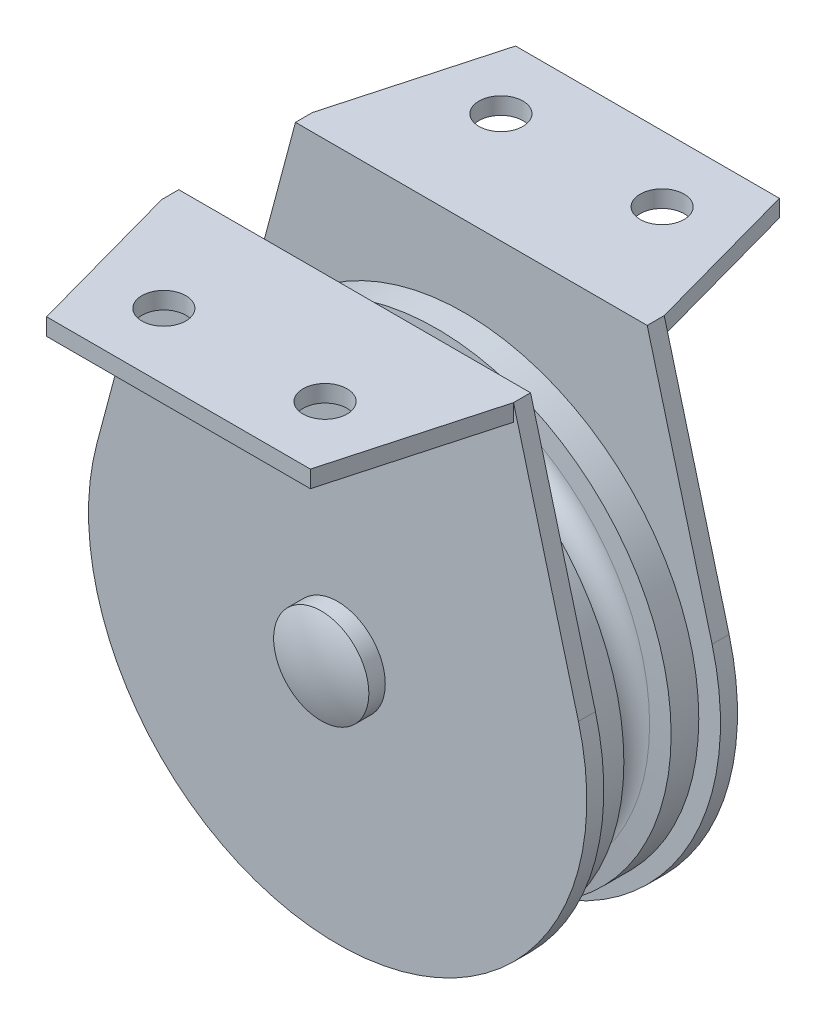
from build123d import *

# Parameters (mm, degrees)
BOSS_EXTRUDE1_DEPTH = 1.8415
SKETCH5_R           = 2.38125
BOSS_EXTRUDE2_DEPTH = 1.8415
SKETCH6_R           = 5.1562
BOSS_EXTRUDE3_DEPTH = 1.778
DOME4_FACE_RADIUS   = 5.1562
DOME4_HEIGHT        = 1.016
SKETCH8_R           = 6.35
BOSS_EXTRUDE4_DEPTH = 1.778
DOME7_FACE_RADIUS   = 6.35
DOME7_HEIGHT        = 3.9624
SKETCH9_R           = 3.57505
BOSS_EXTRUDE5_DEPTH = 16.3195


with BuildPart() as part:
    # Sketch3 → Revolve1 (revolve)
    with BuildSketch(Plane(origin=(0, 0, 0), x_dir=(0, 0, -1), z_dir=(1, 0, 0))):
        with BuildLine():
            Line((-5.55625, 25.4), (-5.55625, 0))
            Line((-5.55625, 0), (5.55625, 0))
            Line((5.55625, 0), (5.55625, 25.4))
            Line((5.55625, 25.4), (2.559789657, 25.4))
            Line((2.559789657, 25.4), (2.372188625, 23.255710388))
            ThreePointArc((2.372188625, 23.255710388), (0, 21.082), (-2.372188625, 23.255710388))
            Line((-2.372188625, 23.255710388), (-2.559789657, 25.4))
            Line((-2.559789657, 25.4), (-5.55625, 25.4))
        make_face()
    revolve(axis=Axis((0, 0, 5.55625), (0, 0, -1)))



with BuildPart() as body_2:
    # Sketch4 → Boss-Extrude1 (new body)
    with BuildSketch(Plane.XY.offset(6.31825)):
        with BuildLine():
            Line((19.05, 33.3375), (-19.05, 33.3375))
            Line((-19.05, 33.3375), (-26.078582277, 6.944976794))
            ThreePointArc((-26.078582277, 6.944976794), (0, -26.9875), (26.078582277, 6.944976794))
            Line((26.078582277, 6.944976794), (19.05, 33.3375))
        make_face()
    extrude(amount=BOSS_EXTRUDE1_DEPTH)

    # Sketch5 → Boss-Extrude2 (add)
    with BuildSketch(Plane(origin=(0, 33.3375, 97.5995), x_dir=(-1, 0, 0), z_dir=(0, -1, 0))):
        Polygon((-14.2875, 72.1995), (14.2875, 72.1995), (19.05, 89.43975), (-19.05, 89.43975), align=None)
        with Locations((-8.73125, 79.34325)):
            Circle(SKETCH5_R, mode=Mode.SUBTRACT)
        with Locations((8.73125, 79.34325)):
            Circle(SKETCH5_R, mode=Mode.SUBTRACT)
    extrude(amount=BOSS_EXTRUDE2_DEPTH)


with BuildPart() as body_3:
    # Mirror1: mirrored copy
    add(body_2.part.mirror(Plane.XY))


with BuildPart() as body_2_1:
    add(body_2.part)

    # Sketch6 → Boss-Extrude3 (add)
    with BuildSketch(Plane.XY.offset(8.15975)):
        Circle(SKETCH6_R)
    extrude(amount=BOSS_EXTRUDE3_DEPTH)

    # Dome4: a dome of height H over a round flat face of radius A is a cap of a sphere of radius (A * A + H * H) / (2 * H)
    dome4_r = (DOME4_FACE_RADIUS * DOME4_FACE_RADIUS + DOME4_HEIGHT * DOME4_HEIGHT) / (2 * DOME4_HEIGHT)
    dome4_base = Plane((0, 0, 9.93775), z_dir=(0, 0, 1))
    with Locations(dome4_base.offset(DOME4_HEIGHT - dome4_r)):
        dome4_ball = Sphere(dome4_r, mode=Mode.PRIVATE)
    add(split(dome4_ball, bisect_by=dome4_base, keep=Keep.TOP, mode=Mode.PRIVATE))


with BuildPart() as body_4:
    # Sketch8 → Boss-Extrude4 (new body)
    with BuildSketch(Plane(origin=(0, 0, -8.15975), x_dir=(-1, 0, 0), z_dir=(0, 0, -1))):
        Circle(SKETCH8_R)
    extrude(amount=BOSS_EXTRUDE4_DEPTH)

    # Dome7: a dome of height H over a round flat face of radius A is a cap of a sphere of radius (A * A + H * H) / (2 * H)
    dome7_r = (DOME7_FACE_RADIUS * DOME7_FACE_RADIUS + DOME7_HEIGHT * DOME7_HEIGHT) / (2 * DOME7_HEIGHT)
    dome7_base = Plane((0, 0, -9.93775), z_dir=(0, 0, -1))
    with Locations(dome7_base.offset(DOME7_HEIGHT - dome7_r)):
        dome7_ball = Sphere(dome7_r, mode=Mode.PRIVATE)
    add(split(dome7_ball, bisect_by=dome7_base, keep=Keep.TOP, mode=Mode.PRIVATE))


with BuildPart() as part_1:
    add(part.part)

    add(body_2_1.part)  # Boss-Extrude5 merges body 2
    # Sketch9 → Boss-Extrude5 (add)
    with BuildSketch(Plane.XY.offset(8.15975)):
        Circle(SKETCH9_R)
    extrude(amount=-BOSS_EXTRUDE5_DEPTH)


solid = Compound([body_3.part, body_4.part, part_1.part])
